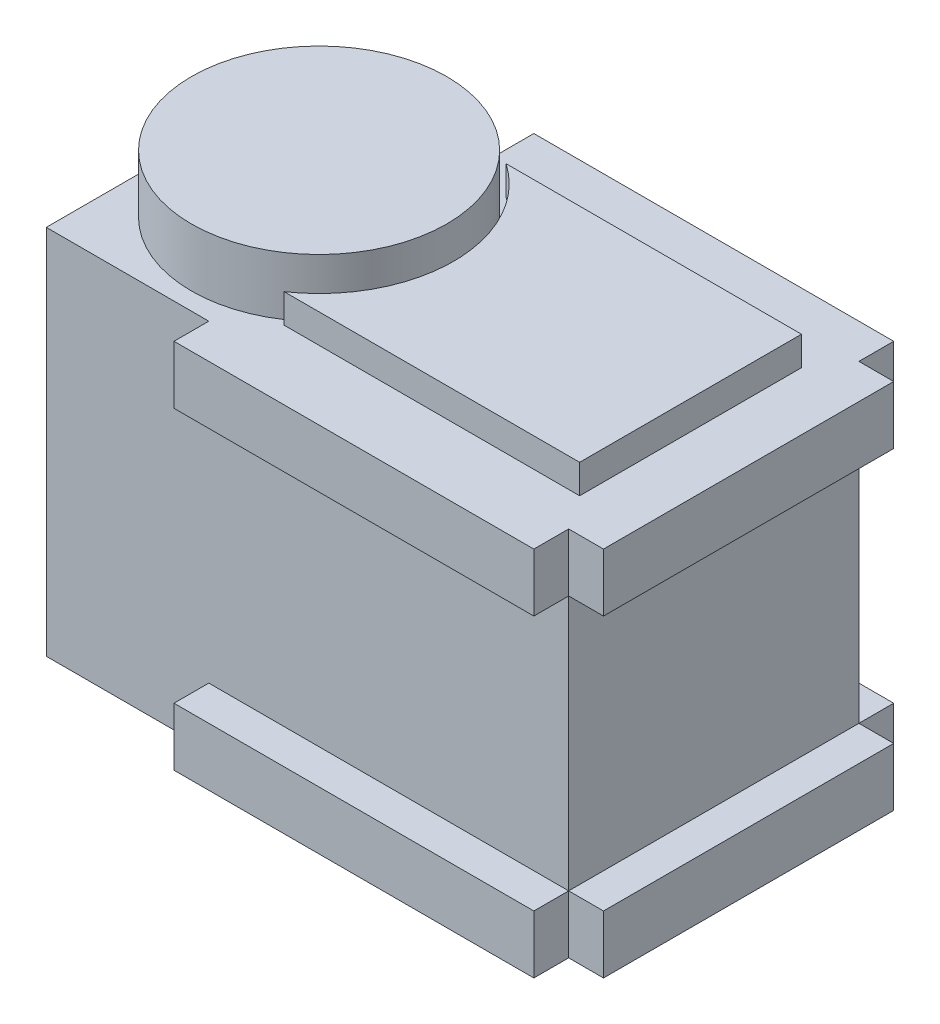
from build123d import *

# Parameters (mm, degrees)
SKETCH1_W           = 45
SKETCH1_H           = 25
BOSS_EXTRUDE1_DEPTH = 32
SKETCH2_R           = 11
BOSS_EXTRUDE2_DEPTH = 5
BOSS_EXTRUDE3_DEPTH = 2.5
SKETCH4_W           = 31
SKETCH4_H           = 5
BOSS_EXTRUDE4_DEPTH = 3
SKETCH5_W           = 31
SKETCH5_H           = 5
BOSS_EXTRUDE5_DEPTH = 3
SKETCH6_W           = 25
SKETCH6_H           = 5
BOSS_EXTRUDE6_DEPTH = 3


with BuildPart() as part:
    # Sketch1 → Boss-Extrude1 (new body)
    with BuildSketch(Plane(origin=(0, 0, 0), x_dir=(1, 0, 0), z_dir=(0, 1, 0))):
        Rectangle(SKETCH1_W, SKETCH1_H)
    extrude(amount=BOSS_EXTRUDE1_DEPTH)

    # Sketch2 → Boss-Extrude2 (add)
    with BuildSketch(Plane(origin=(0, 32, 0), x_dir=(1, 0, 0), z_dir=(0, 1, 0))):
        with Locations((-11.5, 0)):
            Circle(SKETCH2_R)
    extrude(amount=BOSS_EXTRUDE2_DEPTH)

    # Sketch3 → Boss-Extrude3 (add)
    with BuildSketch(Plane(origin=(0, 32, 0), x_dir=(1, 0, 0), z_dir=(0, 1, 0))):
        with BuildLine():
            Line((-4.952747944, 9.555141067), (20.5, 9.555141067))
            Line((20.5, 9.555141067), (20.5, -9.555141067))
            Line((20.5, -9.555141067), (-4.952747944, -9.555141067))
            ThreePointArc((-4.952747944, -9.555141067), (0.083057899, 0), (-4.952747944, 9.555141067))
        make_face()
    extrude(amount=BOSS_EXTRUDE3_DEPTH)

    # Sketch4 → Boss-Extrude4 (add)
    with BuildSketch(Plane.XY.offset(12.5)):
        with Locations((7, 29.5)):
            Rectangle(SKETCH4_W, SKETCH4_H)
        with Locations((7, 2.5)):
            Rectangle(SKETCH4_W, SKETCH4_H)
    extrude(amount=BOSS_EXTRUDE4_DEPTH)

    # Sketch5 → Boss-Extrude5 (add)
    with BuildSketch(Plane(origin=(0, 0, -12.5), x_dir=(-1, 0, 0), z_dir=(0, 0, -1))):
        with Locations((-7, 29.5)):
            Rectangle(SKETCH5_W, SKETCH5_H)
        with Locations((-7, 2.5)):
            Rectangle(SKETCH5_W, SKETCH5_H)
    extrude(amount=BOSS_EXTRUDE5_DEPTH)

    # Sketch6 → Boss-Extrude6 (add)
    with BuildSketch(Plane(origin=(22.5, 0, 0), x_dir=(0, 0, -1), z_dir=(1, 0, 0))):
        with Locations((0, 2.5)):
            Rectangle(SKETCH6_W, SKETCH6_H)
        with Locations((0, 29.5)):
            Rectangle(SKETCH6_W, SKETCH6_H)
    extrude(amount=BOSS_EXTRUDE6_DEPTH)


solid = part.part
